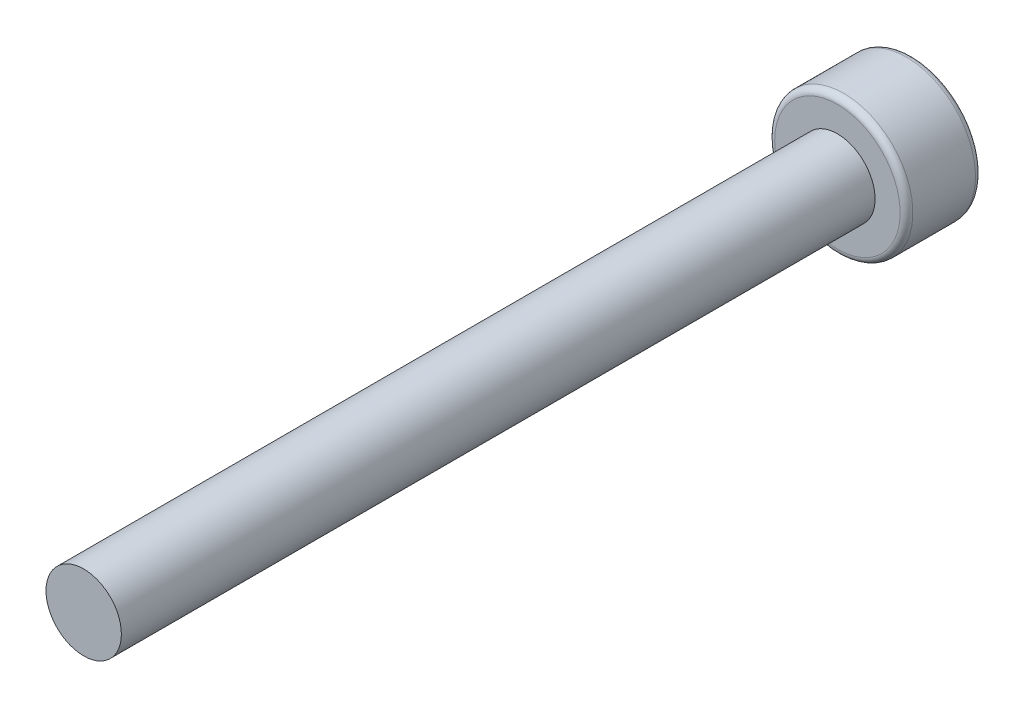
from build123d import *

# Parameters (mm, degrees)
SKETCH1_R           = 1.5
BOSS_EXTRUDE1_DEPTH = 30
SKETCH2_R           = 2.75
BOSS_EXTRUDE2_DEPTH = 3
FILLET1_R           = 0.254
CUT_EXTRUDE1_DEPTH  = 2.54


with BuildPart() as part:
    # Sketch1 → Boss-Extrude1 (new body)
    with BuildSketch(Plane.XY):
        Circle(SKETCH1_R)
    extrude(amount=BOSS_EXTRUDE1_DEPTH)

    # Sketch2 → Boss-Extrude2 (add)
    with BuildSketch(Plane(origin=(0, 0, 0), x_dir=(-1, 0, 0), z_dir=(0, 0, -1))):
        with Locations((0, 0.018427268)):
            Circle(SKETCH2_R)
    extrude(amount=BOSS_EXTRUDE2_DEPTH)

    # Fillet1
    fillet1_edges = [part.edges().sort_by_distance(p)[0] for p in [
        (2.75, 0.018427268, 0),
        (2.75, 0.018427268, -3),
    ]]
    fillet(fillet1_edges, radius=FILLET1_R)

    # Sketch3 → Cut-Extrude1 (cut)
    with BuildSketch(Plane(origin=(0, 0, -3), x_dir=(-1, 0, 0), z_dir=(0, 0, -1))):
        Polygon((1.570116236, -0.229317517), (0.999611396, 1.254315423), (-0.57050484, 1.502060208), (-1.570116236, 0.266172054), (-0.999611396, -1.217460886), (0.57050484, -1.465205671), align=None)
    extrude(amount=-CUT_EXTRUDE1_DEPTH, mode=Mode.SUBTRACT)


solid = part.part
